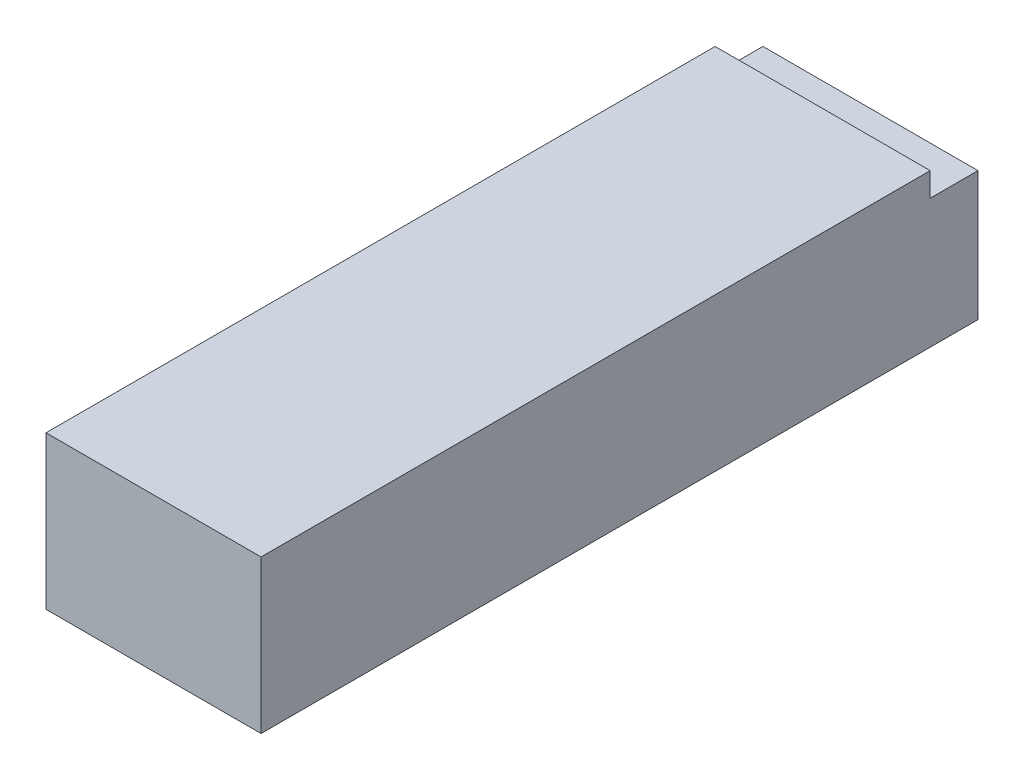
from build123d import *

# Parameters (mm, degrees)
SKETCH1_W           = 45
SKETCH1_H           = 32
BOSS_EXTRUDE1_DEPTH = 150
SKETCH2_W           = 45
SKETCH2_H           = 10
CUT_EXTRUDE1_DEPTH  = 5


with BuildPart() as part:
    # Sketch1 → Boss-Extrude1 (new body)
    with BuildSketch(Plane.XY):
        Rectangle(SKETCH1_W, SKETCH1_H)
    extrude(amount=BOSS_EXTRUDE1_DEPTH)

    # Sketch2 → Cut-Extrude1 (cut)
    with BuildSketch(Plane(origin=(0, 16, 0), x_dir=(1, 0, 0), z_dir=(0, 1, 0))):
        with Locations((0, -5)):
            Rectangle(SKETCH2_W, SKETCH2_H)
    extrude(amount=-CUT_EXTRUDE1_DEPTH, mode=Mode.SUBTRACT)


solid = part.part
